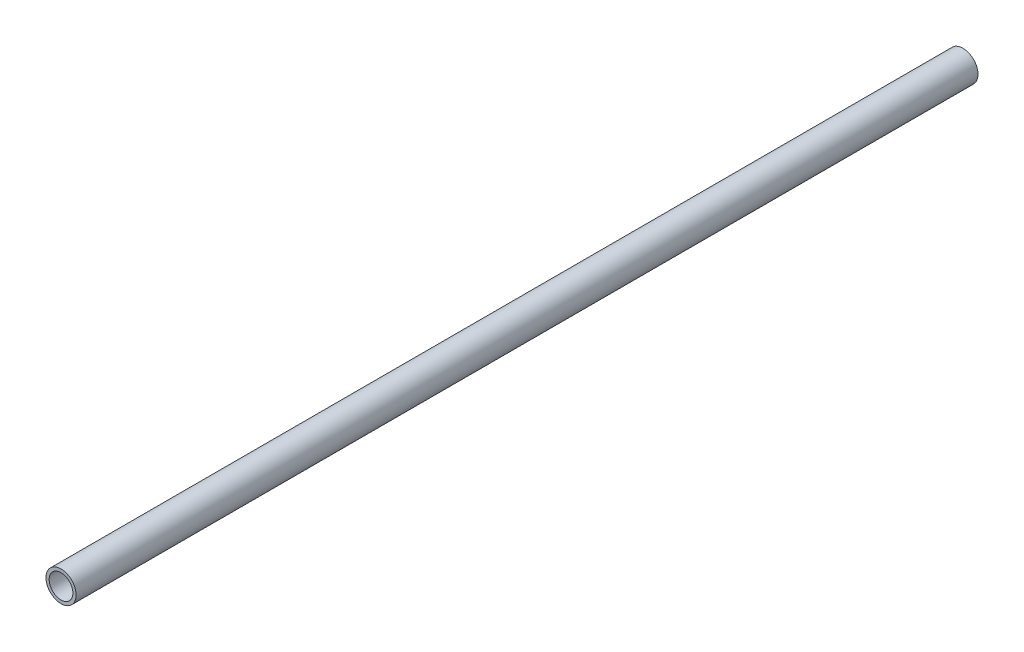
from build123d import *

# Parameters (mm, degrees)
SKETCH1_R           = 6.35
SKETCH1_R_2         = 5
BOSS_EXTRUDE1_DEPTH = 380.28


with BuildPart() as part:
    # Sketch1 → Boss-Extrude1 (new body)
    with BuildSketch(Plane.XY):
        Circle(SKETCH1_R)
        Circle(SKETCH1_R_2, mode=Mode.SUBTRACT)
    extrude(amount=BOSS_EXTRUDE1_DEPTH)


solid = part.part
